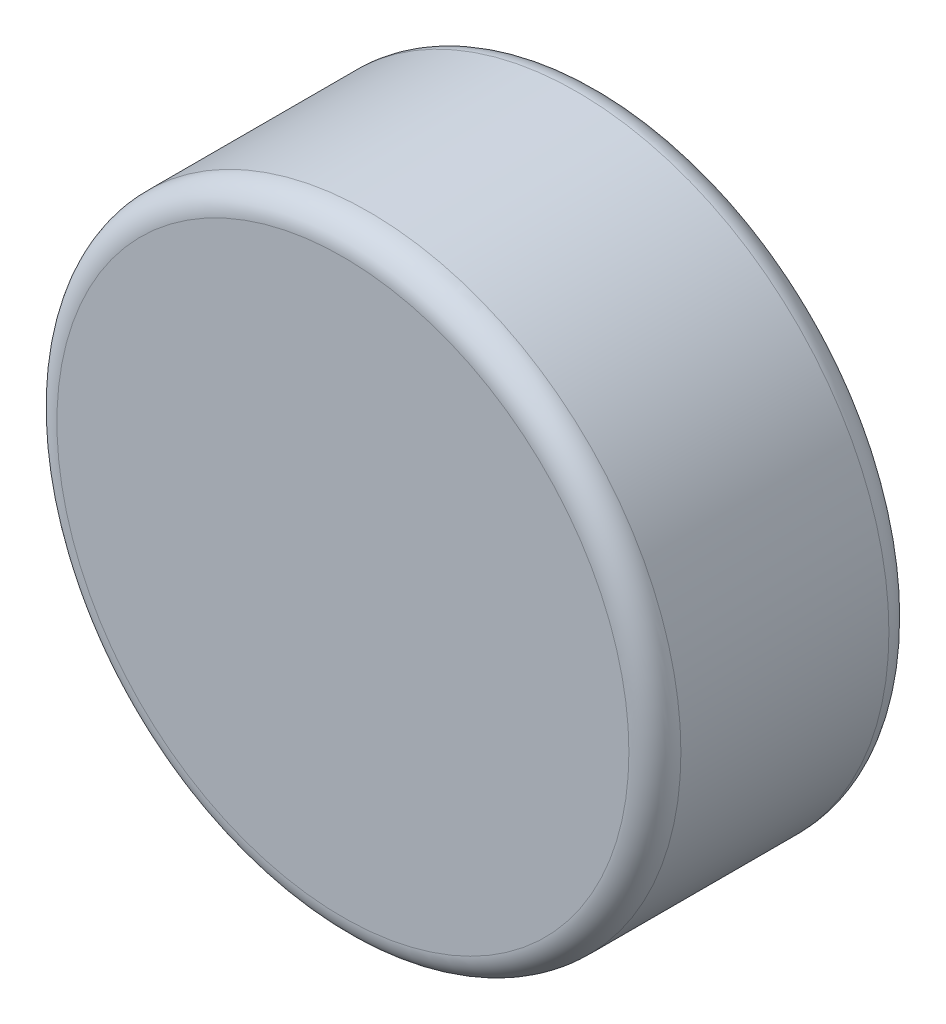
from build123d import *

# Parameters (mm, degrees)
SKETCH1_R           = 3
BOSS_EXTRUDE1_DEPTH = 1.25
FILLET1_R           = 0.25


with BuildPart() as part:
    # Sketch1 → Boss-Extrude1 (new body, symmetric)
    with BuildSketch(Plane.XY):
        Circle(SKETCH1_R)
    extrude(amount=BOSS_EXTRUDE1_DEPTH, both=True)

    # Fillet1
    fillet1_edges = [part.edges().sort_by_distance(p)[0] for p in [
        (-3, 0, -1.25),
        (-3, 0, 1.25),
    ]]
    fillet(fillet1_edges, radius=FILLET1_R)


solid = part.part
